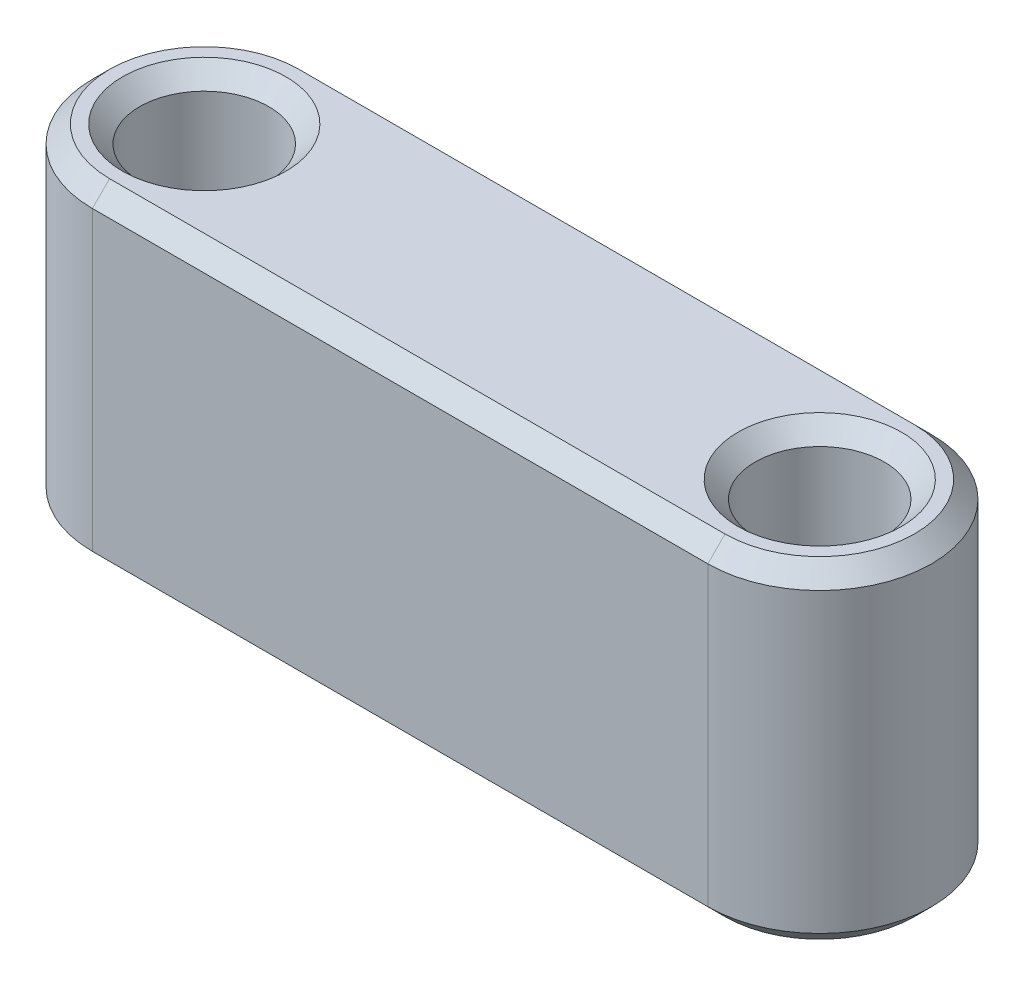
from build123d import *

# Parameters (mm, degrees)
SKETCH1_R           = 1.5
BOSS_EXTRUDE1_DEPTH = 3.85
CHAMFER2_SIZE       = 0.4


with BuildPart() as part:
    # Sketch1 → Boss-Extrude1 (new body, symmetric)
    with BuildSketch(Plane(origin=(0, 0, 0), x_dir=(1, 0, 0), z_dir=(0, 1, 0))):
        with BuildLine():
            Line((-5.963610114, 2.6), (8.336389886, 2.6))
            ThreePointArc((8.336389886, 2.6), (10.936389886, 0), (8.336389886, -2.6))
            Line((8.336389886, -2.6), (-5.963610114, -2.6))
            ThreePointArc((-5.963610114, -2.6), (-8.563610114, 0), (-5.963610114, 2.6))
        make_face()
        with Locations((-5.963610114, 0)):
            Circle(SKETCH1_R, mode=Mode.SUBTRACT)
        with Locations((8.336389886, 0)):
            Circle(SKETCH1_R, mode=Mode.SUBTRACT)
    extrude(amount=BOSS_EXTRUDE1_DEPTH, both=True)

    # Chamfer2
    chamfer2_edges = [part.edges().sort_by_distance(p)[0] for p in [
        (-7.463610114, -3.85, 0),
        (-7.463610114, 3.85, 0),
        (10.936389886, 3.85, 0),
        (6.836389886, -3.85, 0),
        (6.836389886, 3.85, 0),
        (1.186389886, 3.85, -2.6),
        (-8.563610114, 3.85, 0),
        (1.186389886, -3.85, -2.6),
        (10.936389886, -3.85, 0),
        (1.186389886, -3.85, 2.6),
        (-8.563610114, -3.85, 0),
        (1.186389886, 3.85, 2.6),
    ]]
    chamfer(chamfer2_edges, length=CHAMFER2_SIZE)


solid = part.part
